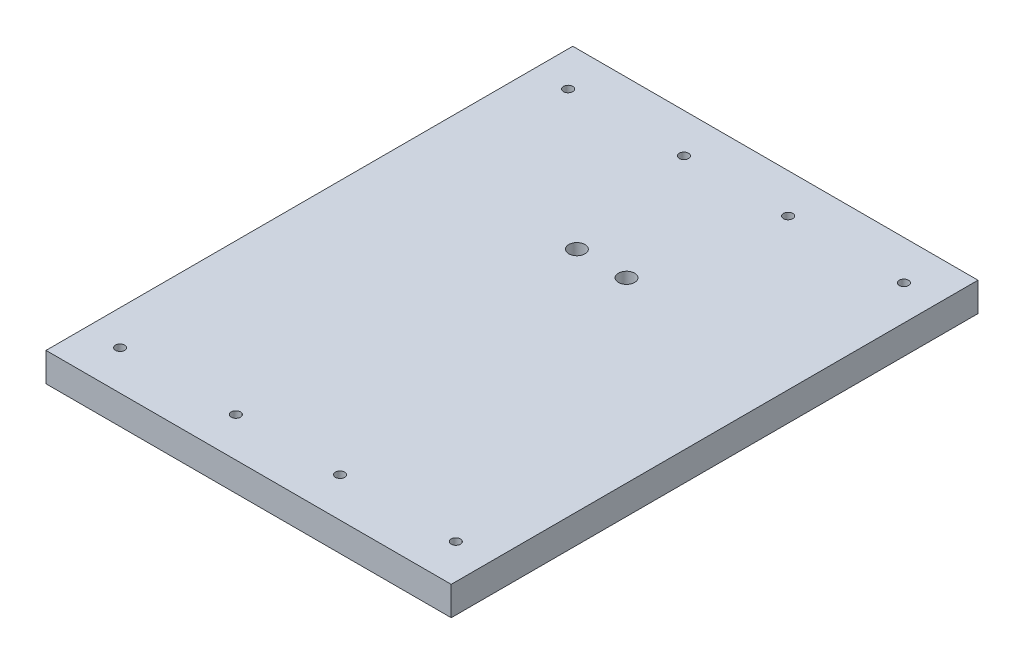
from build123d import *

# Parameters (mm, degrees)
SKETCH1_W           = 88.9
SKETCH1_H           = 115.57
BOSS_EXTRUDE1_DEPTH = 6.35
SKETCH2_R           = 1.016
CUT_EXTRUDE1_DEPTH  = 7.35
SKETCH4_R           = 1.778
CUT_EXTRUDE2_DEPTH  = 7.35


with BuildPart() as part:
    # Sketch1 → Boss-Extrude1 (new body)
    with BuildSketch(Plane(origin=(0, 0, 0), x_dir=(1, 0, 0), z_dir=(0, 1, 0))):
        Rectangle(SKETCH1_W, SKETCH1_H)
    extrude(amount=BOSS_EXTRUDE1_DEPTH)

    # Sketch2 → Cut-Extrude1 (cut, through all)
    with BuildSketch(Plane(origin=(0, 6.35, 0), x_dir=(1, 0, 0), z_dir=(0, 1, 0))):
        with Locations((-36.83, 49.149)):
            Circle(SKETCH2_R)
        with Locations((-11.43, 49.149)):
            Circle(SKETCH2_R)
        with Locations((11.43, 49.149)):
            Circle(SKETCH2_R)
        with Locations((36.83, 49.149)):
            Circle(SKETCH2_R)
        with Locations((36.83, -49.149)):
            Circle(SKETCH2_R)
        with Locations((-11.43, -49.149)):
            Circle(SKETCH2_R)
        with Locations((11.43, -49.149)):
            Circle(SKETCH2_R)
        with Locations((-36.83, -49.149)):
            Circle(SKETCH2_R)
    extrude(amount=-CUT_EXTRUDE1_DEPTH, mode=Mode.SUBTRACT)

    # Sketch4 → Cut-Extrude2 (cut, through all)
    with BuildSketch(Plane(origin=(0, 6.35, 0), x_dir=(1, 0, 0), z_dir=(0, 1, 0))):
        with Locations((-5.445, 19.685)):
            Circle(SKETCH4_R)
        with Locations((5.445, 19.685)):
            Circle(SKETCH4_R)
    extrude(amount=-CUT_EXTRUDE2_DEPTH, mode=Mode.SUBTRACT)


solid = part.part
